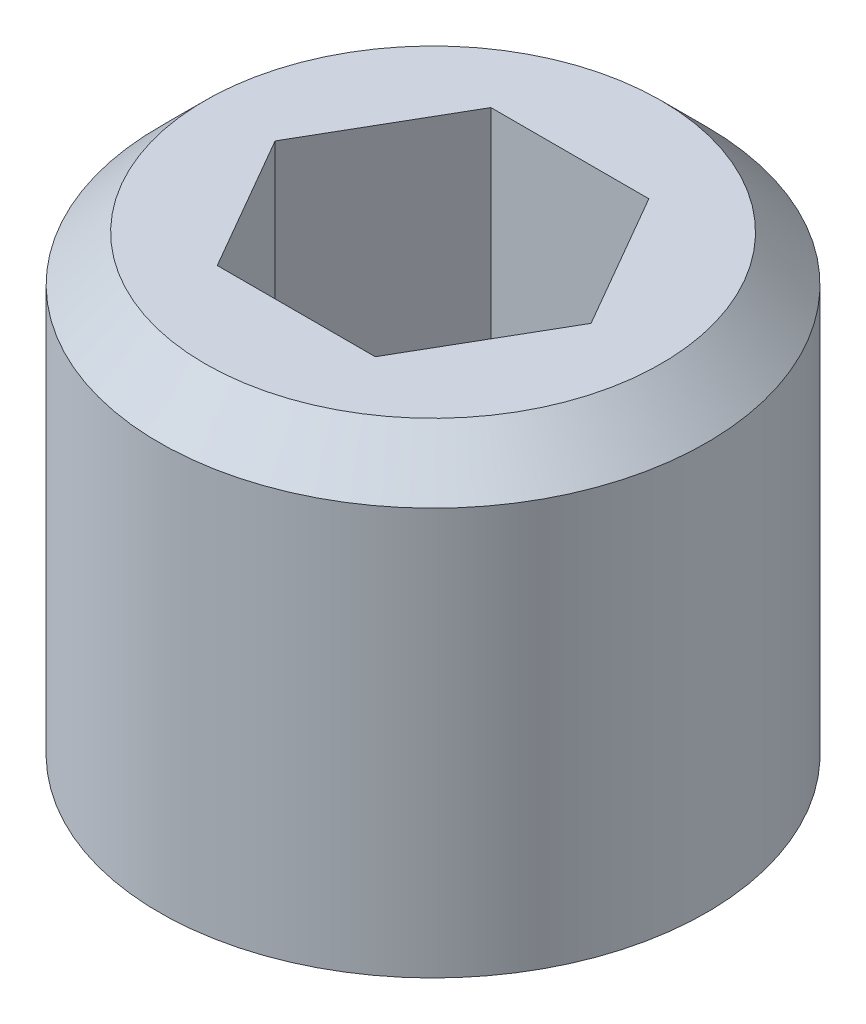
from build123d import *

# Parameters (mm, degrees)
CUT_EXTRUDE1_DEPTH = 2


with BuildPart() as part:
    # Sketch1 → Base-Revolve (revolve)
    with BuildSketch(Plane.XY, mode=Mode.PRIVATE) as base_revolve_sk:
        Polygon((0, 0.346410162), (0, 3), (1.25, 3), (1.5, 2.75), (1.5, 0.519615242), (0.6, 0), align=None)
    revolve(base_revolve_sk.sketch.rotate(Axis((0, 3, 0), (0, 1, 0)), 90), axis=Axis((0, 3, 0), (0, 1, 0)))  # turned: the seam where the file's is

    # Sketch2 → Cut-Extrude1 (cut)
    with BuildSketch(Plane(origin=(0, 3, 0), x_dir=(-1, 0, 0), z_dir=(0, 1, 0))):
        Polygon((-0.433012702, 0.75), (-0.866025404, 0), (-0.433012702, -0.75), (0.433012702, -0.75), (0.866025404, 0), (0.433012702, 0.75), align=None)
    extrude(amount=-CUT_EXTRUDE1_DEPTH, mode=Mode.SUBTRACT)


solid = part.part
